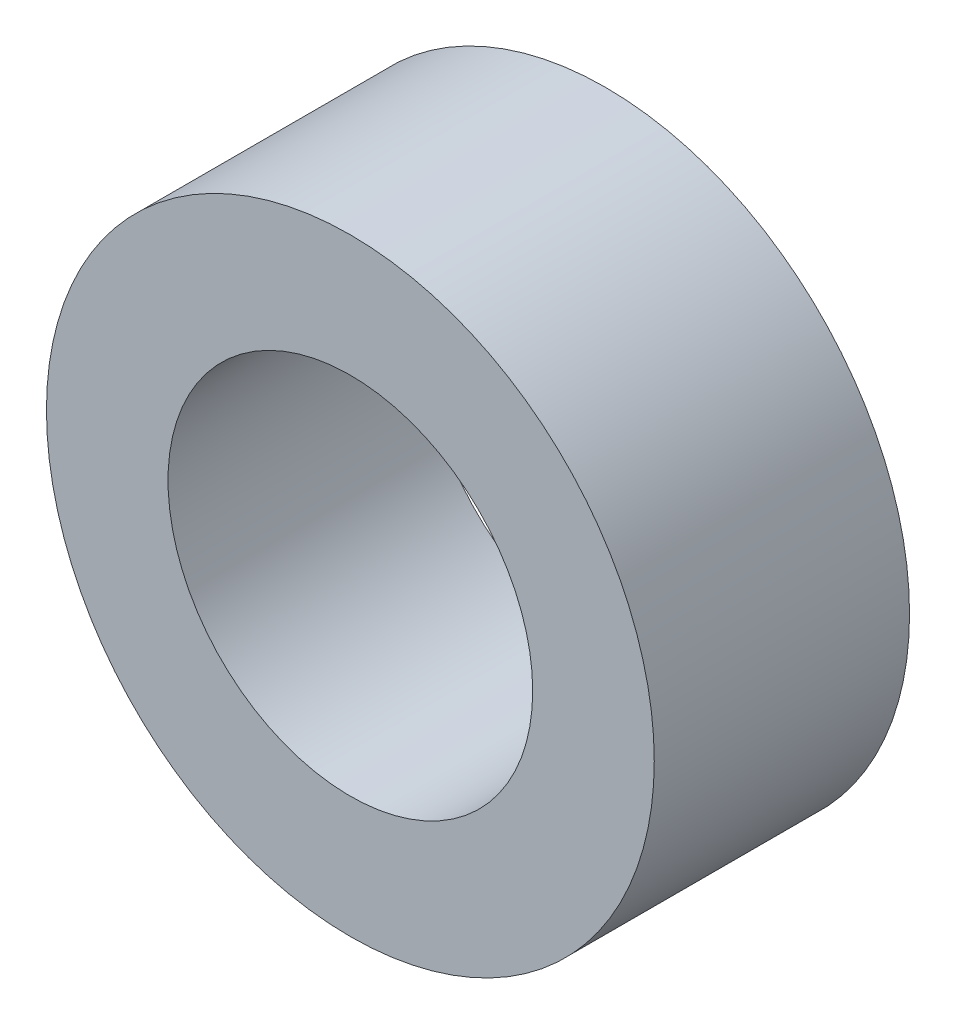
from build123d import *

# Parameters (mm, degrees)
SKETCH_1_R      = 2.5
SKETCH_1_R_2    = 1.5
EXTRUDE_1_DEPTH = 2.1


with BuildPart() as part:
    # 草图1 → 凸台-拉伸1 (new body)
    with BuildSketch(Plane.XY):
        Circle(SKETCH_1_R)
        Circle(SKETCH_1_R_2, mode=Mode.SUBTRACT)
    extrude(amount=EXTRUDE_1_DEPTH)


solid = part.part
